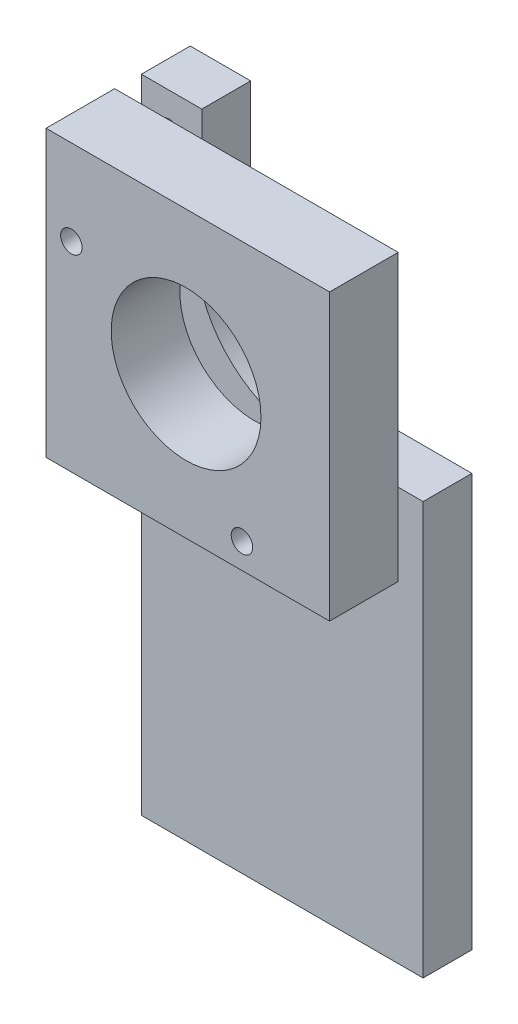
from build123d import *

# Parameters (mm, degrees)
SKETCH1_W           = 32.86
SKETCH1_H           = 33.04
SKETCH1_R           = 8.68
SKETCH1_R_2         = 1.245
BOSS_EXTRUDE1_DEPTH = 7.95
SKETCH2_R           = 1.271766889
BOSS_EXTRUDE2_DEPTH = 3
BOSS_EXTRUDE3_DEPTH = 5.66


with BuildPart() as part:
    # Sketch1 → Boss-Extrude1 (new body)
    with BuildSketch(Plane.XY):
        with Locations((16.43, 16.52)):
            Rectangle(SKETCH1_W, SKETCH1_H)
        with Locations((16.23, 16.48)):
            Circle(SKETCH1_R, mode=Mode.SUBTRACT)
        with Locations((2.935, 23.145)):
            Circle(SKETCH1_R_2, mode=Mode.SUBTRACT)
        with Locations((22.705, 2.935)):
            Circle(SKETCH1_R_2, mode=Mode.SUBTRACT)
    extrude(amount=BOSS_EXTRUDE1_DEPTH)

    # Sketch2 → Boss-Extrude2 (add)
    with BuildSketch(Plane(origin=(0, 0, 0), x_dir=(-1, 0, 0), z_dir=(0, 0, -1))):
        with Locations((-3.305838701, 28.863410922)):
            Circle(SKETCH2_R)
    extrude(amount=BOSS_EXTRUDE2_DEPTH)

    # Sketch3 → Boss-Extrude3 (add)
    with BuildSketch(Plane(origin=(0, 0, -3), x_dir=(-1, 0, 0), z_dir=(0, 0, -1))):
        with BuildLine():
            Line((-0.1, 33.04), (-7.1, 33.04))
            Line((-7.1, 33.04), (-7.1, 23.04))
            ThreePointArc((-7.1, 23.04), (-10.265055125, 9.570142898), (-23.75, 6.47))
            Line((-23.75, 6.47), (-32.75, 6.47))
            Line((-32.75, 6.47), (-32.75, -41.35))
            Line((-32.75, -41.35), (-0.1, -41.35))
            Line((-0.1, -41.35), (-0.1, 33.04))
        make_face()
    extrude(amount=BOSS_EXTRUDE3_DEPTH)


solid = part.part
